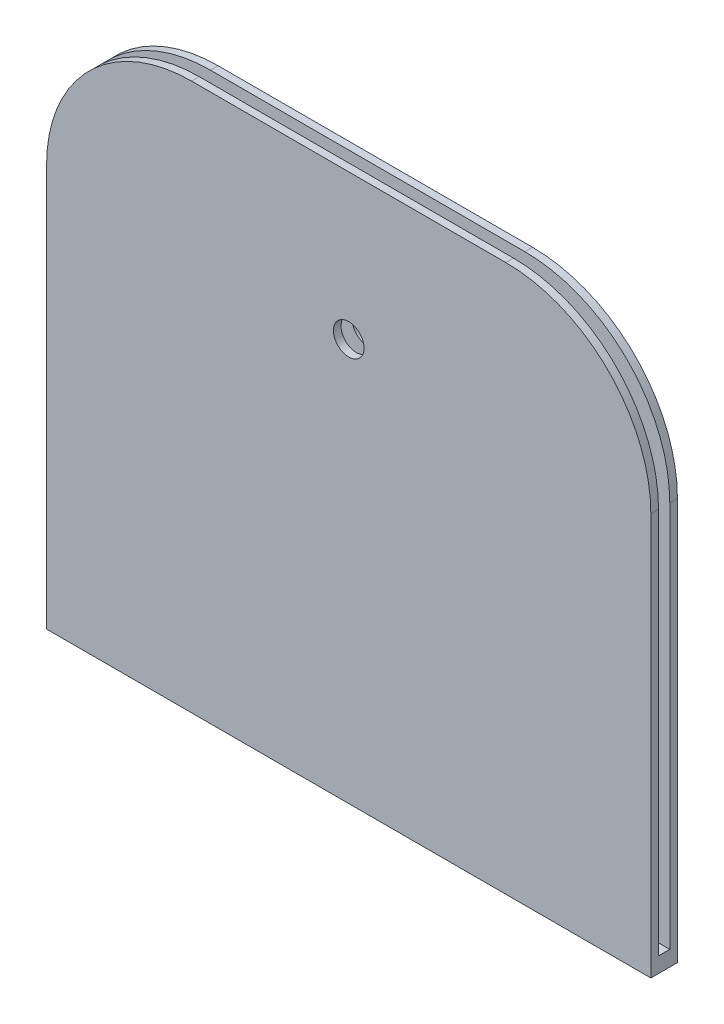
from build123d import *

# Parameters (mm, degrees)
CROQUIS1_W              = 250
CROQUIS1_H              = 11
SALIENTE_EXTRUIR1_DEPTH = 6.35
CROQUIS2_W              = 250
CROQUIS2_H              = 3.175
SALIENTE_EXTRUIR2_DEPTH = 220
REDONDEO1_R             = 60
CROQUIS4_R              = 6.35
CORTAR_EXTRUIR1_DEPTH   = 11


with BuildPart() as part:
    # Croquis1 → Saliente-Extruir1 (new body)
    with BuildSketch(Plane(origin=(0, 0, 0), x_dir=(1, 0, 0), z_dir=(0, 1, 0))):
        with Locations((125, -0.308803141)):
            Rectangle(CROQUIS1_W, CROQUIS1_H)
    extrude(amount=SALIENTE_EXTRUIR1_DEPTH)

    # Croquis2 → Saliente-Extruir2 (add)
    with BuildSketch(Plane(origin=(0, 6.35, 0), x_dir=(1, 0, 0), z_dir=(0, 1, 0))):
        with Locations((125, 3.603696859)):
            Rectangle(CROQUIS2_W, CROQUIS2_H)
        with Locations((125, -4.221303141)):
            Rectangle(CROQUIS2_W, CROQUIS2_H)
    extrude(amount=SALIENTE_EXTRUIR2_DEPTH)

    # Redondeo1
    redondeo1_edges = [part.edges().sort_by_distance(p)[0] for p in [
        (250, 226.35, -3.603696859),
        (0, 226.35, -3.603696859),
        (0, 226.35, 4.221303141),
        (250, 226.35, 4.221303141),
    ]]
    fillet(redondeo1_edges, radius=REDONDEO1_R)

    # Croquis4 → Cortar-Extruir1 (cut)
    with BuildSketch(Plane(origin=(0, 0, -5.191196859), x_dir=(-1, 0, 0), z_dir=(0, 0, -1))):
        with Locations((-125, 166.35)):
            Circle(CROQUIS4_R)
    extrude(amount=-CORTAR_EXTRUIR1_DEPTH, mode=Mode.SUBTRACT)


solid = part.part
